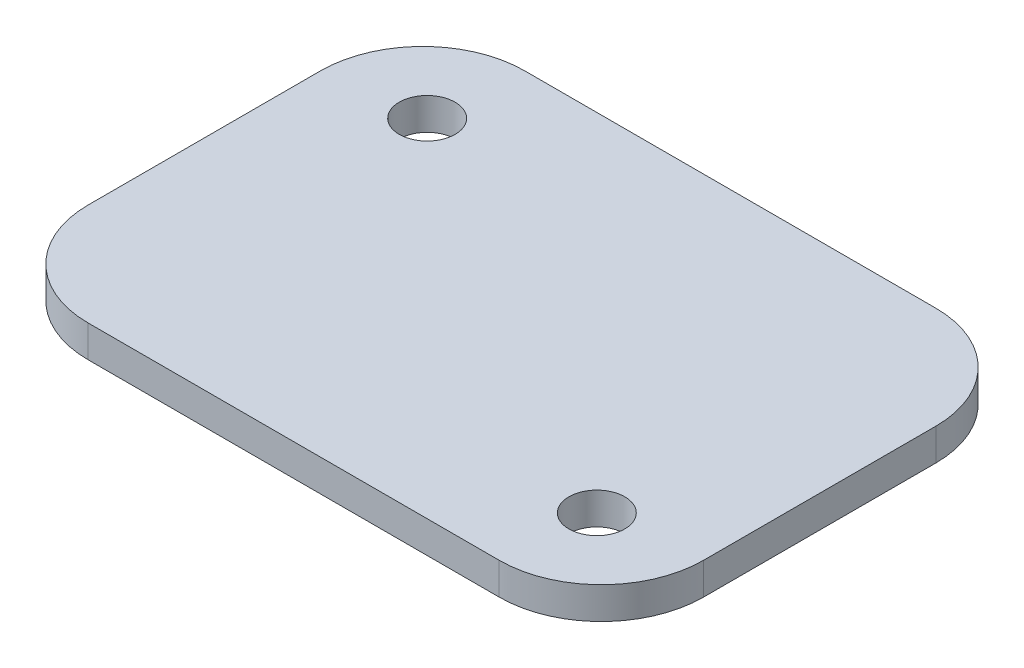
from build123d import *

# Parameters (mm, degrees)
BOSS_EXTRUDE1_DEPTH             = 3.175
F_7_32_0_21875_DIAMETER_HOLE1_D = 5.55625


with BuildPart() as part:
    # Sketch1 → Boss-Extrude1 (new body)
    with BuildSketch(Plane(origin=(0, 0, 0), x_dir=(1, 0, 0), z_dir=(0, 1, 0))):
        with BuildLine():
            Line((-20.447, -21.717), (20.447, -21.717))
            ThreePointArc((20.447, -21.717), (27.631204897, -18.741204897), (30.607, -11.557))
            Line((30.607, -11.557), (30.607, 11.557))
            ThreePointArc((30.607, 11.557), (27.631204897, 18.741204897), (20.447, 21.717))
            Line((20.447, 21.717), (-20.447, 21.717))
            ThreePointArc((-20.447, 21.717), (-27.631204897, 18.741204897), (-30.607, 11.557))
            Line((-30.607, 11.557), (-30.607, -11.557))
            ThreePointArc((-30.607, -11.557), (-27.631204897, -18.741204897), (-20.447, -21.717))
        make_face()
    extrude(amount=BOSS_EXTRUDE1_DEPTH)

    # 7/32 (0.21875) Diameter Hole1 (through all)
    with Locations(Plane(origin=(0, 3.175, 0), x_dir=(1, 0, 0), z_dir=(0, 1, 0))):
        with Locations((-21.214511478, 12.776921686), (21.214511478, -12.776921686)):
            Hole(F_7_32_0_21875_DIAMETER_HOLE1_D / 2)


solid = part.part
